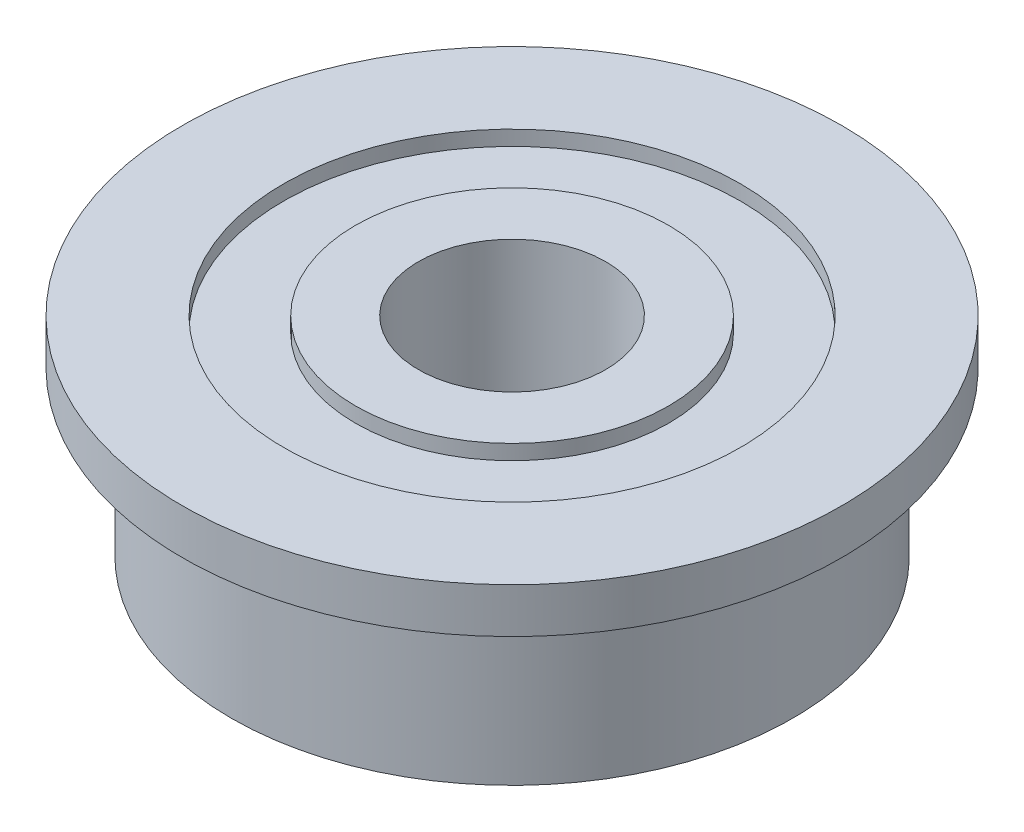
from build123d import *


with BuildPart() as part:
    # Sketch1 → Revolve1 (revolve)
    with BuildSketch(Plane.XY):
        Polygon((2.6543, 0), (2.6543, 0.254), (3.8735, 0.254), (3.8735, 0), (4.7625, 0), (4.7625, 2.7686), (5.588, 2.7686), (5.588, 3.5306), (3.8735, 3.5306), (3.8735, 3.2766), (2.6543, 3.2766), (2.6543, 3.5306), (1.5875, 3.5306), (1.5875, 0), align=None)
    revolve(axis=Axis((0, 3.5306, 0), (0, -1, 0)))


solid = part.part
